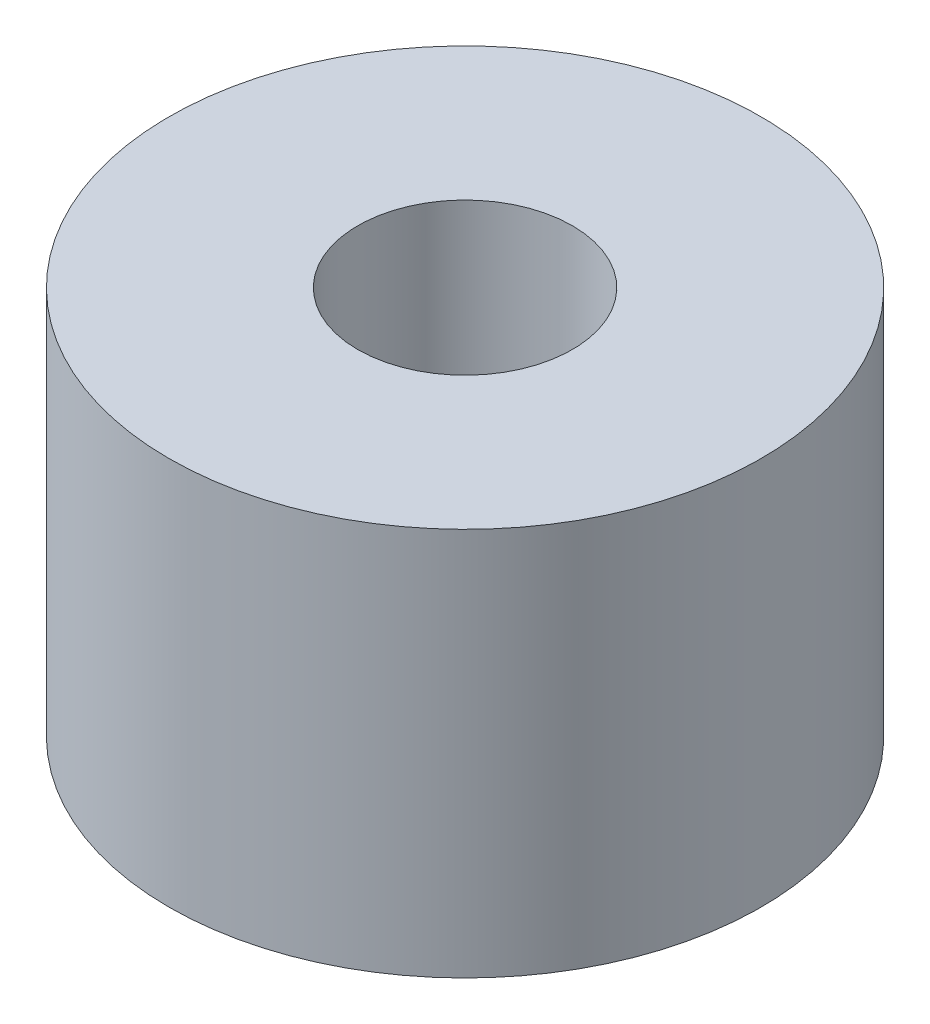
from build123d import *

# Parameters (mm, degrees)
ESQUISSE1_R        = 4
ESQUISSE1_R_2      = 1.45
BOSS_EXTRU_1_DEPTH = 5.25


with BuildPart() as part:
    # Esquisse1 → Boss.-Extru.1 (new body)
    with BuildSketch(Plane(origin=(0, 0, 0), x_dir=(1, 0, 0), z_dir=(0, 1, 0))):
        Circle(ESQUISSE1_R)
        Circle(ESQUISSE1_R_2, mode=Mode.SUBTRACT)
    extrude(amount=BOSS_EXTRU_1_DEPTH)


solid = part.part
